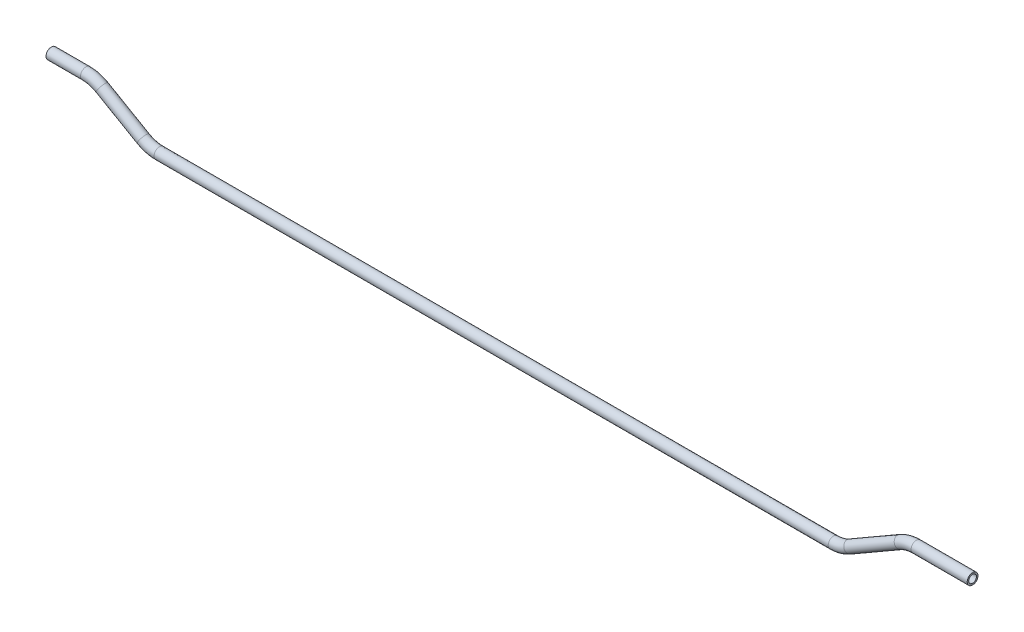
from build123d import *

# Parameters (mm, degrees)
SKETCH2_R   = 3.175
SKETCH2_R_2 = 2.286


with BuildPart() as part:
    # Sweep1: sweep along a path in Sketch1
    with BuildLine(Plane.XY) as sweep1_path:
        Line((-15.200789542, -14.78287466), (5.094778342, -14.78287466))
        ThreePointArc((5.094778342, -14.78287466), (10.025281152, -15.431987669), (14.619778342, -17.335090718))
        Line((14.619778342, -17.335090718), (38.774210458, -31.280658602))
        ThreePointArc((38.774210458, -31.280658602), (43.368707649, -33.183761651), (48.299210458, -33.83287466))
        Line((48.299210458, -33.83287466), (444.490346227, -33.83287466))
        ThreePointArc((444.490346227, -33.83287466), (449.420849036, -33.183761651), (454.015346227, -31.280658602))
        Line((454.015346227, -31.280658602), (483.669039656, -14.160090718))
        ThreePointArc((483.669039656, -14.160090718), (488.263536847, -12.256987669), (493.194039656, -11.60787466))
        Line((493.194039656, -11.60787466), (526.189607541, -11.60787466))
    # Sketch2 → Sweep1 (sweep)
    with BuildSketch(Plane(origin=(-15.200789542, -14.78287466, 0), x_dir=(0, 0, -1), z_dir=(1, 0, 0))):
        Circle(SKETCH2_R)
        Circle(SKETCH2_R_2, mode=Mode.SUBTRACT)
    sweep(path=sweep1_path.line)


solid = part.part
